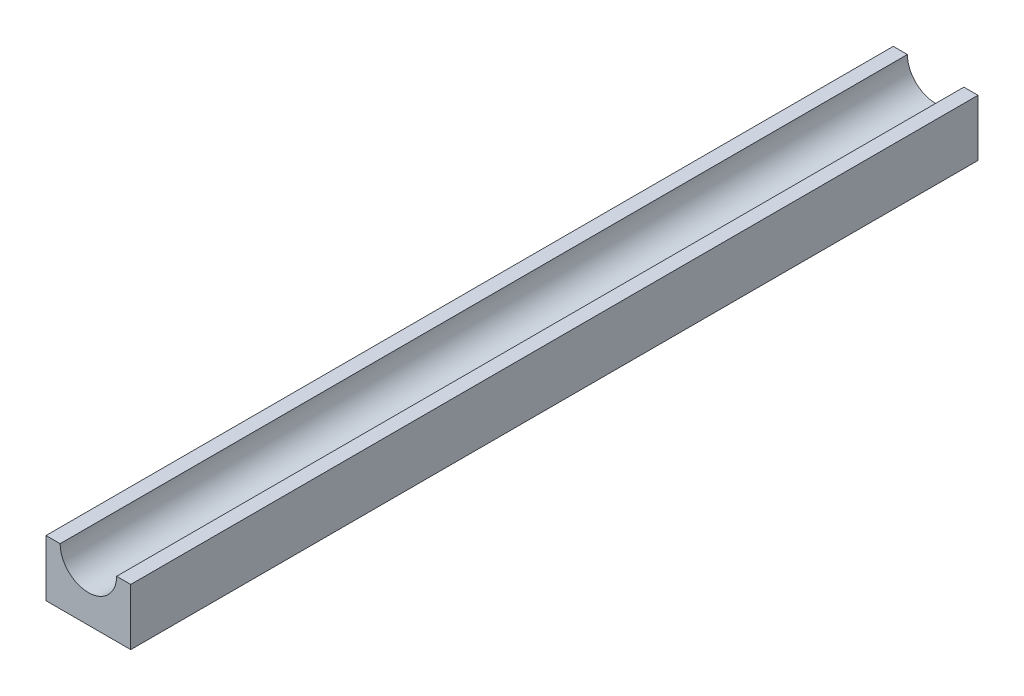
from build123d import *

# Parameters (mm, degrees)
BOSS_EXTRUDE1_DEPTH = 150
BOSS_EXTRUDE6_DEPTH = 1.5
SKETCH7_R           = 0.5
BOSS_EXTRUDE7_DEPTH = 4


with BuildPart() as part:
    # Sketch1 → Boss-Extrude1 (new body)
    with BuildSketch(Plane.XY):
        with BuildLine():
            Line((7.5, 5), (5, 5))
            ThreePointArc((5, 5), (0, 0), (-5, 5))
            Line((-5, 5), (-7.5, 5))
            Line((-7.5, 5), (-7.5, -5))
            Line((-7.5, -5), (7.5, -5))
            Line((7.5, -5), (7.5, 5))
        make_face()
    extrude(amount=BOSS_EXTRUDE1_DEPTH)

    # Sketch6 → Boss-Extrude6 (add, symmetric)
    with BuildSketch(Plane.ZY):
        with BuildLine():
            ThreePointArc((77.5, -8), (75, -5.5), (72.5, -8))
            Line((72.5, -8), (77.5, -8))
        make_face()
        with BuildLine():
            Line((77.5, -8), (72.5, -8))
            ThreePointArc((72.5, -8), (75, -10.5), (77.5, -8))
        make_face()
        with BuildLine():
            Line((77.5, -5), (72.5, -5))
            Line((72.5, -5), (72.5, -8))
            ThreePointArc((72.5, -8), (75, -5.5), (77.5, -8))
            Line((77.5, -8), (77.5, -5))
        make_face()
    boss_extrude6 = extrude(amount=BOSS_EXTRUDE6_DEPTH, both=True)

    # Sketch7 → Boss-Extrude7 (add, symmetric)
    with BuildSketch(Plane.ZY):
        with Locations((75, -8)):
            Circle(SKETCH7_R)
    boss_extrude7 = extrude(amount=BOSS_EXTRUDE7_DEPTH, both=True)

    # Mirror1: Boss-Extrude6 across plane
    add(boss_extrude6.mirror(Plane(origin=(0, 0, 45), x_dir=(1, 0, 0), z_dir=(0, 0, -1))))

    # Mirror2: Boss-Extrude7 across plane
    add(boss_extrude7.mirror(Plane(origin=(0, 0, 45), x_dir=(1, 0, 0), z_dir=(0, 0, -1))))


solid = part.part
